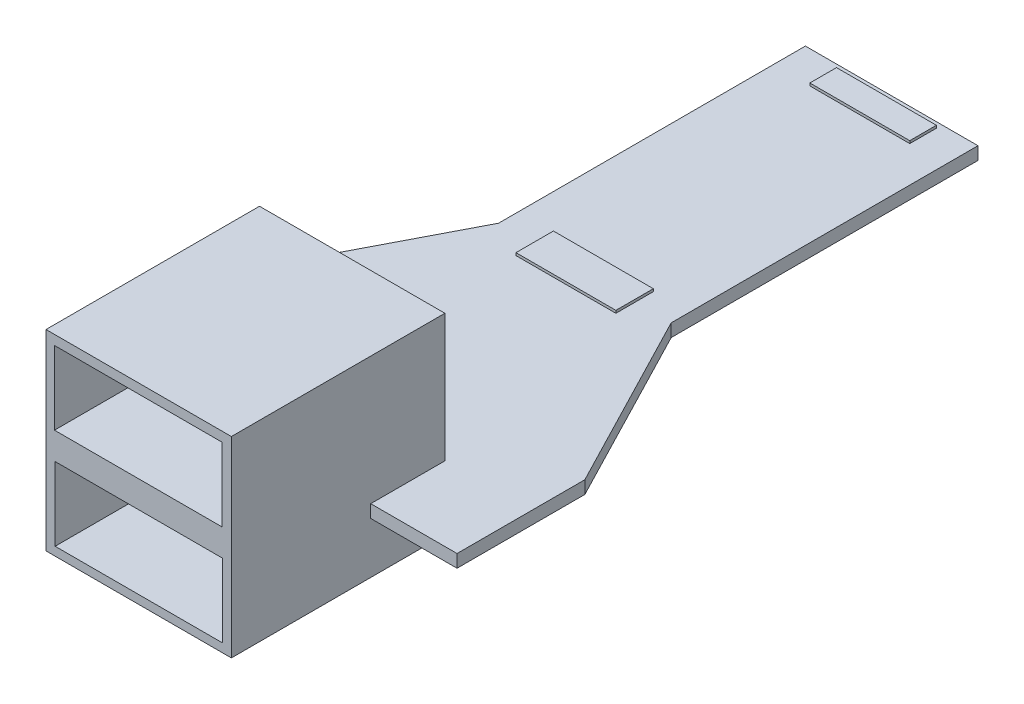
from build123d import *

# Parameters (mm, degrees)
SKETCH1_W           = 28
SKETCH1_H           = 10
SKETCH1_W_2         = 13.5
SKETCH1_H_2         = 24
BOSS_EXTRUDE1_DEPTH = 1
SKETCH2_W           = 14.5
SKETCH2_H           = 16.7
BOSS_EXTRUDE2_DEPTH = 15
SKETCH3_W           = 13.1
SKETCH3_H           = 5.74
CUT_EXTRUDE1_DEPTH  = 10
SKETCH4_W           = 7.814614209
SKETCH4_H           = 2.930480328
SKETCH4_H_2         = 2.083897123
BOSS_EXTRUDE3_DEPTH = 0.2


with BuildPart() as part:
    # Sketch1 → Boss-Extrude1 (new body)
    with BuildSketch(Plane(origin=(0, 0, 0), x_dir=(1, 0, 0), z_dir=(0, 1, 0))):
        Polygon((-4.896995708, 15.74248927), (8.603004292, 15.74248927), (15.853004292, 1.74248927), (-12.146995708, 1.74248927), align=None)
        with Locations((1.853004292, -3.25751073)):
            Rectangle(SKETCH1_W, SKETCH1_H)
        with Locations((1.853004292, 27.74248927)):
            Rectangle(SKETCH1_W_2, SKETCH1_H_2)
    extrude(amount=BOSS_EXTRUDE1_DEPTH)

    # Sketch2 → Boss-Extrude2 (add)
    with BuildSketch(Plane(origin=(0, 11, 0), x_dir=(1, 0, 0), z_dir=(0, 1, 0))):
        with Locations((1.853004292, -10.80751073)):
            Rectangle(SKETCH2_W, SKETCH2_H)
    extrude(amount=-BOSS_EXTRUDE2_DEPTH)

    # Sketch3 → Cut-Extrude1 (cut)
    with BuildSketch(Plane.XY.offset(19.15751073)):
        with Locations((1.816567827, 7.380781329)):
            Rectangle(SKETCH3_W, SKETCH3_H)
        with Locations((1.867135477, -0.457204484)):
            Rectangle(SKETCH3_W, SKETCH3_H)
    extrude(amount=-CUT_EXTRUDE1_DEPTH, mode=Mode.SUBTRACT)

    # Sketch4 → Boss-Extrude3 (add)
    with BuildSketch(Plane(origin=(0, 1, 0), x_dir=(1, 0, 0), z_dir=(0, 1, 0))):
        with Locations((1.885565184, 15.692844408)):
            Rectangle(SKETCH4_W, SKETCH4_H)
        with Locations((1.885565184, 38.257542937)):
            Rectangle(SKETCH4_W, SKETCH4_H_2)
    extrude(amount=BOSS_EXTRUDE3_DEPTH)


solid = part.part
